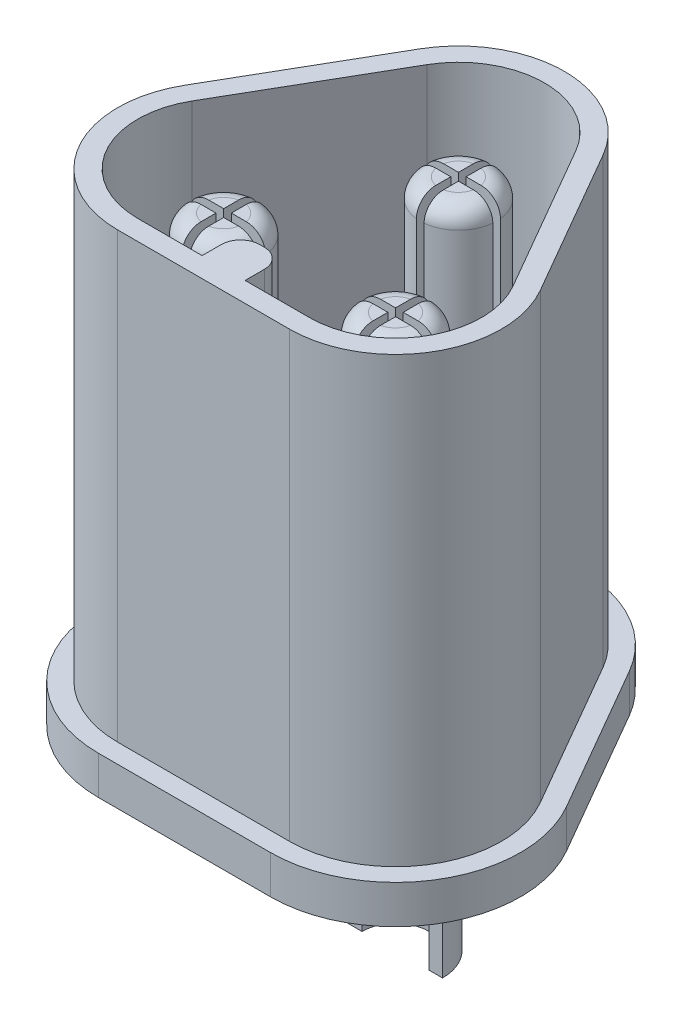
from build123d import *

# Parameters (mm, degrees)
SKETCH1_W           = 1.12
SKETCH1_H           = 1
BOSS_EXTRUDE1_DEPTH = 7.5
FILLET1_R           = 0.5
BOSS_EXTRUDE2_DEPTH = 1.5
BOSS_EXTRUDE3_DEPTH = 3.56
BOSS_EXTRUDE4_DEPTH = 1
SKETCH5_R           = 1.225
SKETCH5_R_2         = 0.875
BOSS_EXTRUDE5_DEPTH = 6.41
CUT_EXTRUDE1_DEPTH  = 2.65
SKETCH7_R           = 1.225
BOSS_EXTRUDE6_DEPTH = 0.25
SKETCH8_R           = 1
BOSS_EXTRUDE7_DEPTH = 6.25
FILLET2_R           = 0.5
SKETCH9_W           = 0.2
SKETCH9_H           = 2
SKETCH9_W_2         = 2
SKETCH9_H_2         = 0.2
CUT_EXTRUDE2_DEPTH  = 5


with BuildPart() as part:
    # Sketch1 → Boss-Extrude1 (new body)
    with BuildSketch(Plane(origin=(0, 0, 0), x_dir=(1, 0, 0), z_dir=(0, 1, 0))):
        with BuildLine():
            ThreePointArc((-3.373443963, 2.51702366), (-4.09114494, 2.047501201), (-4.630127019, 1.380384758))
            ThreePointArc((-4.630127019, 1.380384758), (-4.630127019, -1.380384758), (-2.239230485, -2.760769515))
            ThreePointArc((-2.239230485, -2.760769515), (-1.391999658, -2.627555564), (-0.626530793, -2.240769515))
            Line((-0.626530793, -2.240769515), (-2.239230485, -2.240769515))
            ThreePointArc((-2.239230485, -2.240769515), (-4.179793809, -1.120384758), (-4.179793809, 1.120384758))
            Line((-4.179793809, 1.120384758), (-3.373443963, 2.51702366))
        make_face()
        with BuildLine():
            ThreePointArc((-0.626530793, -2.240769515), (-1.391999658, -2.627555564), (-2.239230485, -2.760769515))
            Line((-2.239230485, -2.760769515), (2.239230485, -2.760769515))
            ThreePointArc((2.239230485, -2.760769515), (1.391999658, -2.627555564), (0.626530793, -2.240769515))
            Line((0.626530793, -2.240769515), (0.56, -2.240769515))
            Line((0.56, -2.240769515), (-0.56, -2.240769515))
            Line((-0.56, -2.240769515), (-0.626530793, -2.240769515))
        make_face()
        with BuildLine():
            ThreePointArc((0.626530793, -2.240769515), (1.391999658, -2.627555564), (2.239230485, -2.760769515))
            ThreePointArc((2.239230485, -2.760769515), (4.19138933, -1.952158846), (5, 0))
            ThreePointArc((5, 0), (4.90592906, 0.71453973), (4.630127019, 1.380384758))
            ThreePointArc((4.630127019, 1.380384758), (4.09114494, 2.047501201), (3.373443963, 2.51702366))
            Line((3.373443963, 2.51702366), (4.179793809, 1.120384758))
            ThreePointArc((4.179793809, 1.120384758), (4.40364763, 0.579953826), (4.48, 0))
            ThreePointArc((4.48, 0), (3.823693804, -1.584463319), (2.239230485, -2.240769515))
            Line((2.239230485, -2.240769515), (0.626530793, -2.240769515))
        make_face()
        with BuildLine():
            Line((4.630127019, 1.380384758), (2.390896534, 5.258845727))
            ThreePointArc((2.390896534, 5.258845727), (2.666698575, 4.593000699), (2.760769515, 3.878460969))
            ThreePointArc((2.760769515, 3.878460969), (2.757303253, 3.740160255), (2.74691317, 3.602206825))
            Line((2.74691317, 3.602206825), (3.373443963, 2.51702366))
            ThreePointArc((3.373443963, 2.51702366), (4.09114494, 2.047501201), (4.630127019, 1.380384758))
        make_face()
        with BuildLine():
            ThreePointArc((2.390896534, 5.258845727), (0, 6.639230485), (-2.390896534, 5.258845727))
            ThreePointArc((-2.390896534, 5.258845727), (-2.699145282, 4.458515332), (-2.74691317, 3.602206825))
            Line((-2.74691317, 3.602206825), (-1.940563324, 4.998845727))
            ThreePointArc((-1.940563324, 4.998845727), (0, 6.119230485), (1.940563324, 4.998845727))
            Line((1.940563324, 4.998845727), (2.74691317, 3.602206825))
            ThreePointArc((2.74691317, 3.602206825), (2.757303253, 3.740160255), (2.760769515, 3.878460969))
            ThreePointArc((2.760769515, 3.878460969), (2.666698575, 4.593000699), (2.390896534, 5.258845727))
        make_face()
        with BuildLine():
            Line((-2.390896534, 5.258845727), (-4.630127019, 1.380384758))
            ThreePointArc((-4.630127019, 1.380384758), (-4.09114494, 2.047501201), (-3.373443963, 2.51702366))
            Line((-3.373443963, 2.51702366), (-2.74691317, 3.602206825))
            ThreePointArc((-2.74691317, 3.602206825), (-2.699145282, 4.458515332), (-2.390896534, 5.258845727))
        make_face()
        with Locations((0, -1.740769515)):
            Rectangle(SKETCH1_W, SKETCH1_H)
    extrude(amount=BOSS_EXTRUDE1_DEPTH)

    # Fillet1
    fillet1_edges = [part.edges().sort_by_distance(p)[0] for p in [
        (-0.56, 3.75, 1.240769515),
        (0.56, 3.75, 1.240769515),
    ]]
    fillet(fillet1_edges, radius=FILLET1_R)

    # Sketch2 → Boss-Extrude2 (add)
    with BuildSketch(Plane.XZ):
        with BuildLine():
            Line((2.239230485, 2.760769515), (-2.239230485, 2.760769515))
            ThreePointArc((-2.239230485, 2.760769515), (-4.630127019, 1.380384758), (-4.630127019, -1.380384758))
            Line((-4.630127019, -1.380384758), (-2.390896534, -5.258845727))
            ThreePointArc((-2.390896534, -5.258845727), (0, -6.639230485), (2.390896534, -5.258845727))
            Line((2.390896534, -5.258845727), (4.630127019, -1.380384758))
            ThreePointArc((4.630127019, -1.380384758), (4.630127019, 1.380384758), (2.239230485, 2.760769515))
        make_face()
    extrude(amount=BOSS_EXTRUDE2_DEPTH)

    # Sketch3 → Boss-Extrude3 (add)
    with BuildSketch(Plane.XZ.offset(1.5)):
        with BuildLine():
            Line((2.239230485, 2.760769515), (-2.239230485, 2.760769515))
            ThreePointArc((-2.239230485, 2.760769515), (-4.630127019, 1.380384758), (-4.630127019, -1.380384758))
            Line((-4.630127019, -1.380384758), (-2.390896534, -5.258845727))
            ThreePointArc((-2.390896534, -5.258845727), (0, -6.639230485), (2.390896534, -5.258845727))
            Line((2.390896534, -5.258845727), (4.630127019, -1.380384758))
            ThreePointArc((4.630127019, -1.380384758), (4.630127019, 1.380384758), (2.239230485, 2.760769515))
        make_face()
        with BuildLine():
            Line((-2.239230485, 2.240769515), (-0.56, 2.240769515))
            Line((-0.56, 2.240769515), (0.56, 2.240769515))
            Line((0.56, 2.240769515), (2.239230485, 2.240769515))
            ThreePointArc((2.239230485, 2.240769515), (4.179793809, 1.120384758), (4.179793809, -1.120384758))
            Line((4.179793809, -1.120384758), (1.940563324, -4.998845727))
            ThreePointArc((1.940563324, -4.998845727), (0, -6.119230485), (-1.940563324, -4.998845727))
            Line((-1.940563324, -4.998845727), (-4.179793809, -1.120384758))
            ThreePointArc((-4.179793809, -1.120384758), (-4.179793809, 1.120384758), (-2.239230485, 2.240769515))
        make_face(mode=Mode.SUBTRACT)
    extrude(amount=BOSS_EXTRUDE3_DEPTH)

    # Sketch4 → Boss-Extrude4 (add)
    with BuildSketch(Plane.XZ.offset(5.06)):
        with BuildLine():
            Line((-2.239230485, 3.260769515), (2.239230485, 3.260769515))
            ThreePointArc((2.239230485, 3.260769515), (5.063139721, 1.630384758), (5.063139721, -1.630384758))
            Line((5.063139721, -1.630384758), (2.823909236, -5.508845727))
            ThreePointArc((2.823909236, -5.508845727), (0, -7.139230485), (-2.823909236, -5.508845727))
            Line((-2.823909236, -5.508845727), (-5.063139721, -1.630384758))
            ThreePointArc((-5.063139721, -1.630384758), (-5.063139721, 1.630384758), (-2.239230485, 3.260769515))
        make_face()
        with BuildLine():
            Line((4.630127019, -1.380384758), (2.390896534, -5.258845727))
            ThreePointArc((2.390896534, -5.258845727), (0, -6.639230485), (-2.390896534, -5.258845727))
            Line((-2.390896534, -5.258845727), (-4.630127019, -1.380384758))
            ThreePointArc((-4.630127019, -1.380384758), (-4.630127019, 1.380384758), (-2.239230485, 2.760769515))
            Line((-2.239230485, 2.760769515), (2.239230485, 2.760769515))
            ThreePointArc((2.239230485, 2.760769515), (4.630127019, 1.380384758), (4.630127019, -1.380384758))
        make_face(mode=Mode.SUBTRACT)
    extrude(amount=-BOSS_EXTRUDE4_DEPTH)

    # Sketch5 → Boss-Extrude5 (add)
    with BuildSketch(Plane.XZ.offset(1.5)):
        with Locations((-2.239230485, 0)):
            Circle(SKETCH5_R)
        with Locations((-2.239230485, 0)):
            Circle(SKETCH5_R_2, mode=Mode.SUBTRACT)
        with Locations((2.239230485, 0)):
            Circle(SKETCH5_R)
        with Locations((2.239230485, 0)):
            Circle(SKETCH5_R_2, mode=Mode.SUBTRACT)
        with Locations((0, -3.878460969)):
            Circle(SKETCH5_R)
        with Locations((0, -3.878460969)):
            Circle(SKETCH5_R_2, mode=Mode.SUBTRACT)
    extrude(amount=BOSS_EXTRUDE5_DEPTH)

    # Sketch6 → Cut-Extrude1 (cut)
    with BuildSketch(Plane.XZ.offset(7.91)):
        with BuildLine():
            ThreePointArc((-3.114230485, 0), (-2.239230485, 0.875), (-1.364230485, 0))
            Line((-1.364230485, 0), (-1.014230485, 0))
            ThreePointArc((-1.014230485, 0), (-2.239230485, 1.225), (-3.464230485, 0))
            Line((-3.464230485, 0), (-3.114230485, 0))
        make_face()
        with BuildLine():
            ThreePointArc((1.364230485, 0), (2.239230485, 0.875), (3.114230485, 0))
            Line((3.114230485, 0), (3.464230485, 0))
            ThreePointArc((3.464230485, 0), (2.239230485, 1.225), (1.014230485, 0))
            Line((1.014230485, 0), (1.364230485, 0))
        make_face()
        with BuildLine():
            Line((1.225, -3.878460969), (0.875, -3.878460969))
            ThreePointArc((0.875, -3.878460969), (0, -4.753460969), (-0.875, -3.878460969))
            Line((-0.875, -3.878460969), (-1.225, -3.878460969))
            ThreePointArc((-1.225, -3.878460969), (0, -5.103460969), (1.225, -3.878460969))
        make_face()
    extrude(amount=-CUT_EXTRUDE1_DEPTH, mode=Mode.SUBTRACT)

    # Sketch7 → Boss-Extrude6 (add)
    with BuildSketch(Plane(origin=(0, 0, 0), x_dir=(1, 0, 0), z_dir=(0, 1, 0))):
        with Locations((-2.239230485, 0)):
            Circle(SKETCH7_R)
        with Locations((2.239230485, 0)):
            Circle(SKETCH7_R)
        with Locations((0, 3.878460969)):
            Circle(SKETCH7_R)
    extrude(amount=BOSS_EXTRUDE6_DEPTH)

    # Sketch8 → Boss-Extrude7 (add)
    with BuildSketch(Plane(origin=(0, 0.25, 0), x_dir=(1, 0, 0), z_dir=(0, 1, 0))):
        with Locations((0, 3.878460969)):
            Circle(SKETCH8_R)
        with Locations((-2.239230485, 0)):
            Circle(SKETCH8_R)
        with Locations((2.239230485, 0)):
            Circle(SKETCH8_R)
    extrude(amount=BOSS_EXTRUDE7_DEPTH)

    # Fillet2
    fillet2_edges = [part.edges().sort_by_distance(p)[0] for p in [
        (-1, 6.5, -3.878460969),
        (-3.239230485, 6.5, 0),
        (1.239230485, 6.5, 0),
    ]]
    fillet(fillet2_edges, radius=FILLET2_R)

    # Sketch9 → Cut-Extrude2 (cut)
    with BuildSketch(Plane(origin=(0, 6.5, 0), x_dir=(1, 0, 0), z_dir=(0, 1, 0))):
        with Locations((0, 3.878460969)):
            Rectangle(SKETCH9_W, SKETCH9_H)
        with Locations((0, 3.878460969)):
            Rectangle(SKETCH9_W_2, SKETCH9_H_2)
        with Locations((-2.239230485, 0)):
            Rectangle(SKETCH9_W, SKETCH9_H)
        with Locations((-2.239230485, 0)):
            Rectangle(SKETCH9_W_2, SKETCH9_H_2)
        with Locations((2.239230485, 0)):
            Rectangle(SKETCH9_W, SKETCH9_H)
        with Locations((2.239230485, 0)):
            Rectangle(SKETCH9_W_2, SKETCH9_H_2)
    extrude(amount=-CUT_EXTRUDE2_DEPTH, mode=Mode.SUBTRACT)


solid = part.part
